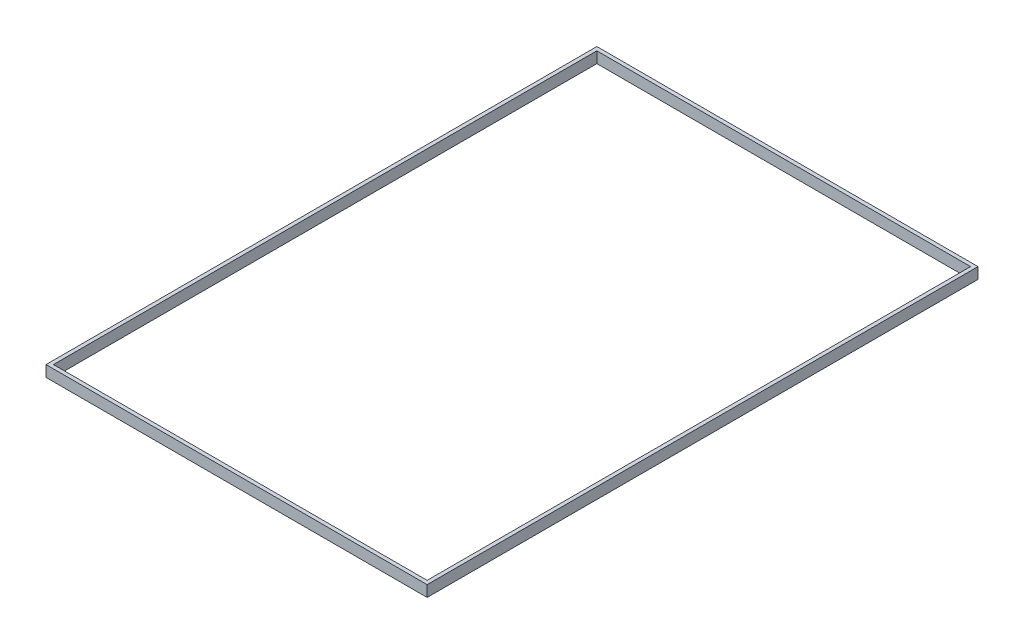
from build123d import *

# Parameters (mm, degrees)
SKETCH1_W           = 102.75
SKETCH1_H           = 148.5
SKETCH1_W_2         = 100.75
SKETCH1_H_2         = 146.5
BOSS_EXTRUDE1_DEPTH = 3


with BuildPart() as part:
    # Sketch1 → Boss-Extrude1 (new body)
    with BuildSketch(Plane(origin=(0, 0, 0), x_dir=(1, 0, 0), z_dir=(0, 1, 0))):
        with Locations((51.375, 74.25)):
            Rectangle(SKETCH1_W, SKETCH1_H)
        with Locations((51.375, 74.25)):
            Rectangle(SKETCH1_W_2, SKETCH1_H_2, mode=Mode.SUBTRACT)
    extrude(amount=BOSS_EXTRUDE1_DEPTH)


solid = part.part
